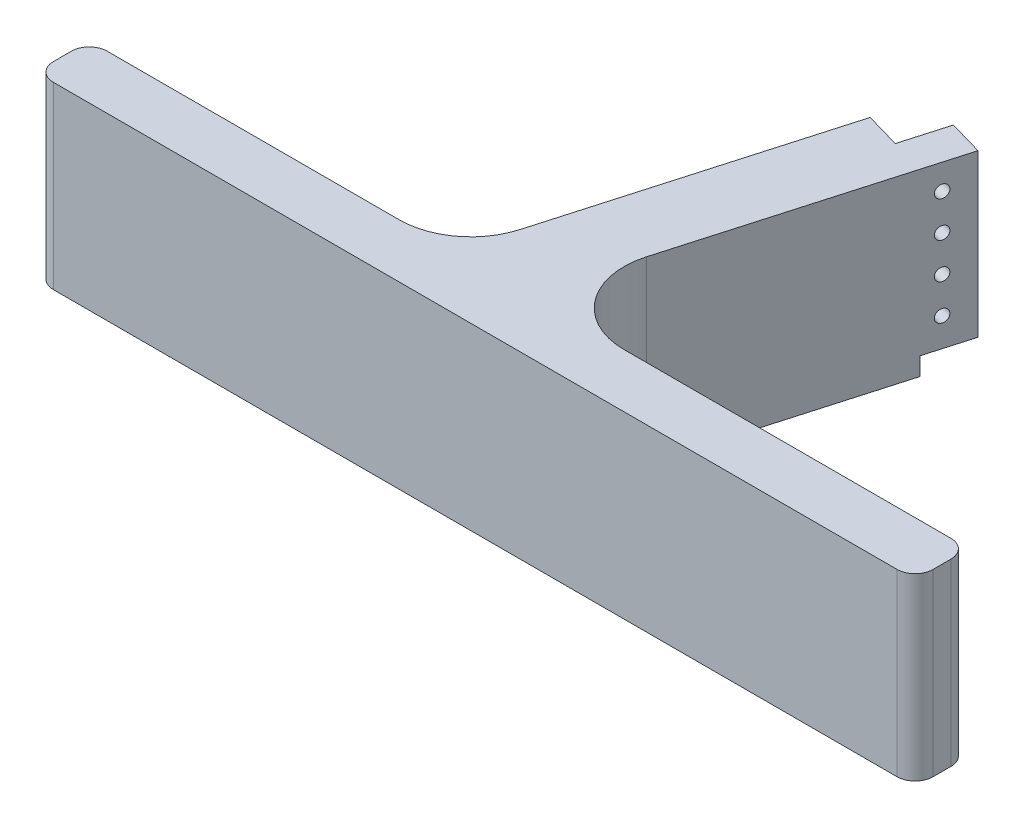
from build123d import *

# Parameters (mm, degrees)
EXTRUDE_1_DEPTH     = 50
FILLET_1_R          = 20
FILLET_2_R          = 5
SKETCH_2_R          = 1.75
CUT_EXTRUDE_1_DEPTH = 10
SKETCH_3_W          = 13.074735308
SKETCH_3_H          = 5
CUT_EXTRUDE_2_DEPTH = 10


with BuildPart() as part:
    # 草图1 → 凸台-拉伸1 (new body)
    with BuildSketch(Plane.XZ.offset(21.952986856)):
        Polygon((27.73572569, 121.735034283), (18.122569365, 118.980542412), (14.521144153, 131.549489855), (4.715724701, 128.739908146), (-21.141245178, 218.980542412), (-122.460743693, 218.980542412), (-122.460743693, 233.980542412), (122.460743693, 233.980542412), (122.460743693, 218.980542412), (-0.12837561, 218.980542412), align=None)
    extrude(amount=-EXTRUDE_1_DEPTH)

    # 圆角1
    fillet_1_edges = [part.edges().sort_by_distance(p)[0] for p in [
        (-21.141245178, 3.047013144, 218.980542412),
        (-0.12837561, 3.047013144, 218.980542412),
    ]]
    fillet(fillet_1_edges, radius=FILLET_1_R)

    # 圆角2
    fillet_2_edges = [part.edges().sort_by_distance(p)[0] for p in [
        (-122.460743693, 3.047013144, 218.980542412),
        (-122.460743693, 3.047013144, 233.980542412),
        (122.460743693, 3.047013144, 233.980542412),
        (122.460743693, 3.047013144, 218.980542412),
    ]]
    fillet(fillet_2_edges, radius=FILLET_2_R)

    # 草图2 → 切除-拉伸1 (cut)
    with BuildSketch(Plane(origin=(57.866012783, 0, 16.580554444), x_dir=(0.275449187, 0, -0.961315633), z_dir=(0.961315633, 0, 0.275449187))):
        with Locations((-117.460743693, -9)):
            Circle(SKETCH_2_R)
        with Locations((-117.460743693, 1)):
            Circle(SKETCH_2_R)
        with Locations((-117.460743693, 11)):
            Circle(SKETCH_2_R)
        with Locations((-117.460743693, 21)):
            Circle(SKETCH_2_R)
    extrude(amount=-CUT_EXTRUDE_1_DEPTH, mode=Mode.SUBTRACT)

    # 草图3 → 切除-拉伸2 (cut)
    with BuildSketch(Plane(origin=(57.866012783, 0, 16.580554444), x_dir=(0.275449187, 0, -0.961315633), z_dir=(0.961315633, 0, 0.275449187))):
        with Locations((-115.923376039, -19.452986856)):
            Rectangle(SKETCH_3_W, SKETCH_3_H)
    extrude(amount=-CUT_EXTRUDE_2_DEPTH, mode=Mode.SUBTRACT)


solid = part.part
